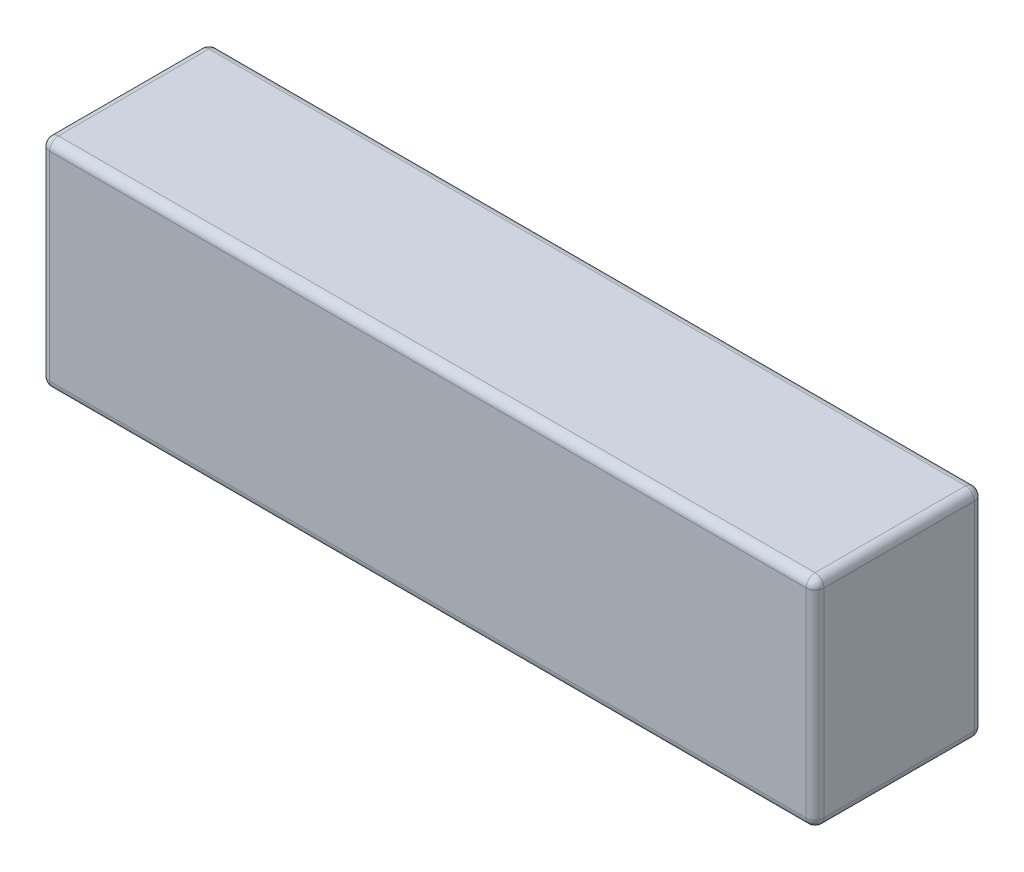
from build123d import *

# Parameters (mm, degrees)
SKETCH1_W           = 175
SKETCH1_H           = 38
BOSS_EXTRUDE1_DEPTH = 49
FILLET1_R           = 2


with BuildPart() as part:
    # Sketch1 → Boss-Extrude1 (new body)
    with BuildSketch(Plane(origin=(0, 0, 0), x_dir=(1, 0, 0), z_dir=(0, 1, 0))):
        with Locations((87.5, 19)):
            Rectangle(SKETCH1_W, SKETCH1_H)
    extrude(amount=BOSS_EXTRUDE1_DEPTH)

    # Fillet1
    fillet1_edges = [part.edges().sort_by_distance(p)[0] for p in [
        (175, 49, -19),
        (87.5, 49, -38),
        (0, 49, -19),
        (87.5, 0, -38),
        (175, 0, -19),
        (87.5, 0, 0),
        (0, 0, -19),
        (87.5, 49, 0),
        (0, 24.5, -38),
        (175, 24.5, -38),
        (175, 24.5, 0),
        (0, 24.5, 0),
    ]]
    fillet(fillet1_edges, radius=FILLET1_R)


solid = part.part
